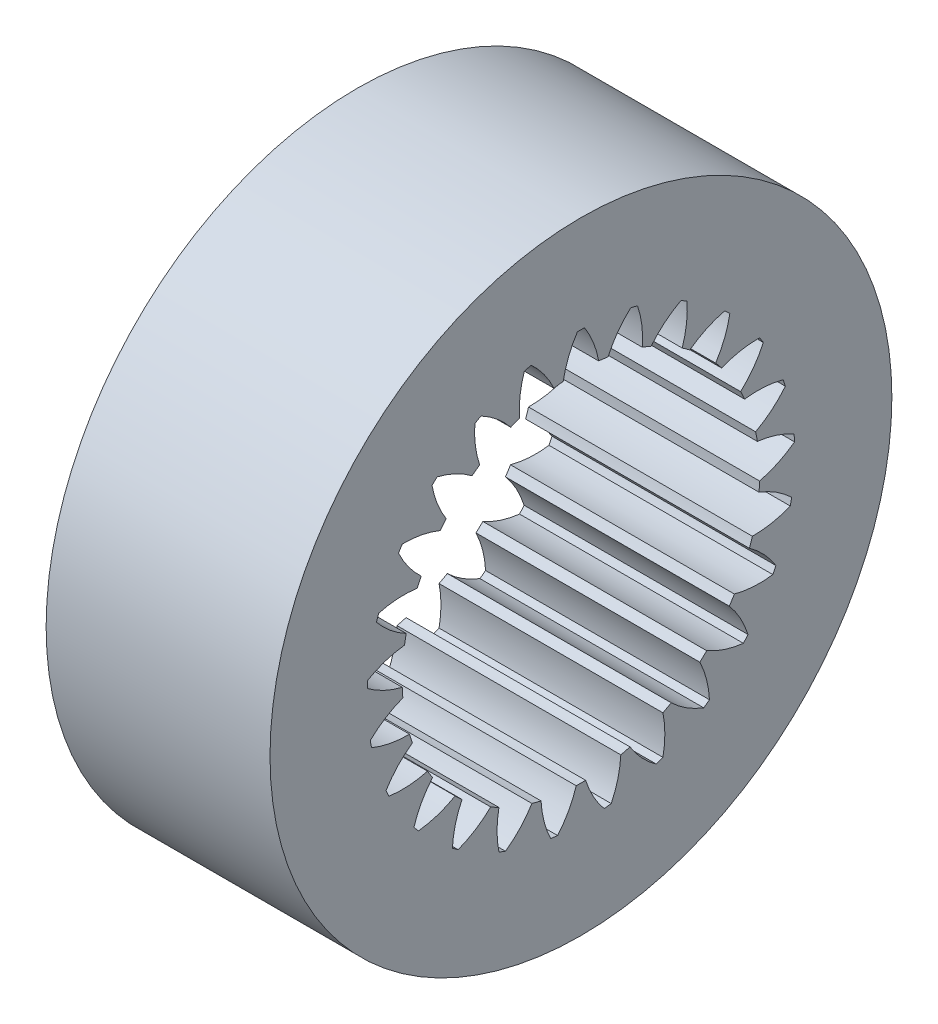
from build123d import *

# Parameters (mm, degrees)
SKETCH1_R           = 5
BOSS_EXTRUDE1_DEPTH = 3.6


with BuildPart() as part:
    # Sketch1 → Boss-Extrude1 (new body)
    with BuildSketch(Plane(origin=(0.839797347, 0, 0), x_dir=(0, 0, -1), z_dir=(1, 0, 0))):
        with Locations((0.288939632, 1.171096215)):
            Circle(SKETCH1_R)
        with BuildLine():
            ThreePointArc((0.724361258, 4.012932419), (0.881490528, 4.282366003), (1.089004557, 4.515222165))
            ThreePointArc((1.089004557, 4.515222165), (1.144059809, 4.501569415), (1.198882356, 4.487010341))
            ThreePointArc((1.198882356, 4.487010341), (1.268548975, 4.182986285), (1.276441784, 3.871182232))
            ThreePointArc((1.276441784, 3.871182232), (1.347297721, 3.844203612), (1.417417612, 3.815365953))
            ThreePointArc((1.417417612, 3.815365953), (1.636615785, 4.037258326), (1.895519351, 4.211192243))
            ThreePointArc((1.895519351, 4.211192243), (1.94544964, 4.184276734), (1.994929142, 4.156541247))
            ThreePointArc((1.994929142, 4.156541247), (1.986799348, 3.844743283), (1.916901675, 3.540772266))
            ThreePointArc((1.916901675, 3.540772266), (1.978822232, 3.497020074), (2.039567544, 3.451650296))
            ThreePointArc((2.039567544, 3.451650296), (2.307061592, 3.612059143), (2.601086833, 3.716141906))
            ThreePointArc((2.601086833, 3.716141906), (2.642754856, 3.677654841), (2.683782333, 3.638485663))
            ThreePointArc((2.683782333, 3.638485663), (2.59836695, 3.338505203), (2.455070724, 3.061466838))
            ThreePointArc((2.455070724, 3.061466838), (2.504165205, 3.003690186), (2.551719086, 2.944639038))
            ThreePointArc((2.551719086, 2.944639038), (2.850701375, 3.033485281), (3.161373603, 3.061176989))
            ThreePointArc((3.161373603, 3.061176989), (3.192161204, 3.01353665), (3.222158749, 2.965394925))
            ThreePointArc((3.222158749, 2.965394925), (3.064824741, 2.696080845), (2.857133789, 2.463382472))
            ThreePointArc((2.857133789, 2.463382472), (2.890317408, 2.395211678), (2.921691873, 2.326189562))
            ThreePointArc((2.921691873, 2.326189562), (3.233376245, 2.337890665), (3.541174782, 2.287451346))
            ThreePointArc((3.541174782, 2.287451346), (3.559147463, 2.23365115), (3.57623022, 2.179561801))
            ThreePointArc((3.57623022, 2.179561801), (3.356863461, 1.957836094), (3.097827771, 1.784099008))
            ThreePointArc((3.097827771, 1.784099008), (3.113015478, 1.709817495), (3.126239154, 1.635161322))
            ThreePointArc((3.126239154, 1.635161322), (3.431041335, 1.568982063), (3.716626066, 1.443581004))
            ThreePointArc((3.716626066, 1.443581004), (3.720654538, 1.387001417), (3.723749134, 1.330363074))
            ThreePointArc((3.723749134, 1.330363074), (3.456133244, 1.170157583), (3.16202898, 1.066298324))
            ThreePointArc((3.16202898, 1.066298324), (3.158266476, 0.990573472), (3.152508471, 0.914974166))
            ThreePointArc((3.152508471, 0.914974166), (3.431276619, 0.775072829), (3.676703205, 0.582589441))
            ThreePointArc((3.676703205, 0.582589441), (3.666534344, 0.526785565), (3.655446335, 0.471157025))
            ThreePointArc((3.655446335, 0.471157025), (3.356396605, 0.38253805), (3.045703419, 0.355082476))
            ThreePointArc((3.045703419, 0.355082476), (3.023227116, 0.282672356), (2.998849227, 0.210880099))
            ThreePointArc((2.998849227, 0.210880099), (3.234067313, 0.006047202), (3.423914699, -0.241424077))
            ThreePointArc((3.423914699, -0.241424077), (3.400187452, -0.292945879), (3.375613538, -0.34406927))
            ThreePointArc((3.375613538, -0.34406927), (3.063920362, -0.355533474), (2.756160251, -0.304860227))
            ThreePointArc((2.756160251, -0.304860227), (2.716382418, -0.36940582), (2.674916396, -0.432880057))
            ThreePointArc((2.674916396, -0.432880057), (2.851804803, -0.689774112), (2.974144181, -0.97668375))
            ThreePointArc((2.974144181, -0.97668375), (2.938349417, -1.020686174), (2.901833668, -1.064092145))
            ThreePointArc((2.901833668, -1.064092145), (2.597081874, -0.99768124), (2.311592537, -0.872063158))
            ThreePointArc((2.311592537, -0.872063158), (2.257012561, -0.924688589), (2.20106387, -0.975856485))
            ThreePointArc((2.20106387, -0.975856485), (2.308508049, -1.268670099), (2.355652385, -1.57699051))
            ThreePointArc((2.355652385, -1.57699051), (2.310039222, -1.61070872), (2.263876056, -1.643669916))
            ThreePointArc((2.263876056, -1.643669916), (1.985214321, -1.503556742), (1.739934103, -1.310886872))
            ThreePointArc((1.739934103, -1.310886872), (1.673981445, -1.34828549), (1.607065546, -1.383931979))
            ThreePointArc((1.607065546, -1.383931979), (1.638314384, -1.694266596), (1.607301426, -2.004624873))
            ThreePointArc((1.607301426, -2.004624873), (1.554735906, -2.025940232), (1.501825925, -2.046385578))
            ThreePointArc((1.501825925, -2.046385578), (1.26676359, -1.841373962), (1.077104349, -1.593758461))
            ThreePointArc((1.077104349, -1.593758461), (1.003923057, -1.613580373), (0.930244524, -1.631465655))
            ThreePointArc((0.930244524, -1.631465655), (0.883334541, -1.939821809), (0.776112947, -2.232717001))
            ThreePointArc((0.776112947, -2.232717001), (0.719897956, -2.240290185), (0.663565687, -2.246935026))
            ThreePointArc((0.663565687, -2.246935026), (0.486872584, -1.989906601), (0.364751308, -1.702904061))
            ThreePointArc((0.364751308, -1.702904061), (0.288939632, -1.703903785), (0.213127956, -1.702904061))
            ThreePointArc((0.213127956, -1.702904061), (0.09100668, -1.989906601), (-0.085686424, -2.246935026))
            ThreePointArc((-0.085686424, -2.246935026), (-0.142018692, -2.240290185), (-0.198233683, -2.232717001))
            ThreePointArc((-0.198233683, -2.232717001), (-0.305455277, -1.939821809), (-0.35236526, -1.631465655))
            ThreePointArc((-0.35236526, -1.631465655), (-0.426043794, -1.613580373), (-0.499225085, -1.593758461))
            ThreePointArc((-0.499225085, -1.593758461), (-0.688884326, -1.841373962), (-0.923946661, -2.046385578))
            ThreePointArc((-0.923946661, -2.046385578), (-0.976856643, -2.025940232), (-1.029422162, -2.004624873))
            ThreePointArc((-1.029422162, -2.004624873), (-1.060435121, -1.694266596), (-1.029186283, -1.383931979))
            ThreePointArc((-1.029186283, -1.383931979), (-1.096102181, -1.34828549), (-1.162054839, -1.310886872))
            ThreePointArc((-1.162054839, -1.310886872), (-1.407335057, -1.503556742), (-1.685996792, -1.643669916))
            ThreePointArc((-1.685996792, -1.643669916), (-1.732159958, -1.61070872), (-1.777773121, -1.57699051))
            ThreePointArc((-1.777773121, -1.57699051), (-1.730628785, -1.268670099), (-1.623184606, -0.975856485))
            ThreePointArc((-1.623184606, -0.975856485), (-1.679133298, -0.924688589), (-1.733713273, -0.872063158))
            ThreePointArc((-1.733713273, -0.872063158), (-2.01920261, -0.99768124), (-2.323954404, -1.064092145))
            ThreePointArc((-2.323954404, -1.064092145), (-2.360470153, -1.020686174), (-2.396264917, -0.97668375))
            ThreePointArc((-2.396264917, -0.97668375), (-2.273925539, -0.689774112), (-2.097037132, -0.432880057))
            ThreePointArc((-2.097037132, -0.432880057), (-2.138503154, -0.36940582), (-2.178280987, -0.304860227))
            ThreePointArc((-2.178280987, -0.304860227), (-2.486041098, -0.355533474), (-2.797734274, -0.34406927))
            ThreePointArc((-2.797734274, -0.34406927), (-2.822308188, -0.292945879), (-2.846035436, -0.241424077))
            ThreePointArc((-2.846035436, -0.241424077), (-2.656188049, 0.006047202), (-2.420969963, 0.210880099))
            ThreePointArc((-2.420969963, 0.210880099), (-2.445347852, 0.282672356), (-2.467824155, 0.355082476))
            ThreePointArc((-2.467824155, 0.355082476), (-2.778517341, 0.38253805), (-3.077567071, 0.471157025))
            ThreePointArc((-3.077567071, 0.471157025), (-3.08865508, 0.526785565), (-3.098823941, 0.582589441))
            ThreePointArc((-3.098823941, 0.582589441), (-2.853397355, 0.775072829), (-2.574629207, 0.914974166))
            ThreePointArc((-2.574629207, 0.914974166), (-2.580387212, 0.990573472), (-2.584149716, 1.066298324))
            ThreePointArc((-2.584149716, 1.066298324), (-2.878253981, 1.170157583), (-3.14586987, 1.330363074))
            ThreePointArc((-3.14586987, 1.330363074), (-3.142775274, 1.387001417), (-3.138746802, 1.443581004))
            ThreePointArc((-3.138746802, 1.443581004), (-2.853162071, 1.568982063), (-2.54835989, 1.635161322))
            ThreePointArc((-2.54835989, 1.635161322), (-2.535136214, 1.709817495), (-2.519948507, 1.784099008))
            ThreePointArc((-2.519948507, 1.784099008), (-2.778984197, 1.957836094), (-2.998350957, 2.179561801))
            ThreePointArc((-2.998350957, 2.179561801), (-2.981268199, 2.23365115), (-2.963295518, 2.287451346))
            ThreePointArc((-2.963295518, 2.287451346), (-2.655496982, 2.337890665), (-2.343812609, 2.326189562))
            ThreePointArc((-2.343812609, 2.326189562), (-2.312438144, 2.395211678), (-2.279254525, 2.463382472))
            ThreePointArc((-2.279254525, 2.463382472), (-2.486945477, 2.696080845), (-2.644279485, 2.965394925))
            ThreePointArc((-2.644279485, 2.965394925), (-2.61428194, 3.01353665), (-2.583494339, 3.061176989))
            ThreePointArc((-2.583494339, 3.061176989), (-2.272822111, 3.033485281), (-1.973839822, 2.944639038))
            ThreePointArc((-1.973839822, 2.944639038), (-1.926285941, 3.003690186), (-1.87719146, 3.061466838))
            ThreePointArc((-1.87719146, 3.061466838), (-2.020487687, 3.338505203), (-2.105903069, 3.638485663))
            ThreePointArc((-2.105903069, 3.638485663), (-2.064875592, 3.677654841), (-2.023207569, 3.716141906))
            ThreePointArc((-2.023207569, 3.716141906), (-1.729182328, 3.612059143), (-1.46168828, 3.451650296))
            ThreePointArc((-1.46168828, 3.451650296), (-1.400942968, 3.497020074), (-1.339022412, 3.540772266))
            ThreePointArc((-1.339022412, 3.540772266), (-1.408920084, 3.844743283), (-1.417049878, 4.156541247))
            ThreePointArc((-1.417049878, 4.156541247), (-1.367570376, 4.184276734), (-1.317640087, 4.211192243))
            ThreePointArc((-1.317640087, 4.211192243), (-1.058736521, 4.037258326), (-0.839538348, 3.815365953))
            ThreePointArc((-0.839538348, 3.815365953), (-0.769418457, 3.844203612), (-0.698562521, 3.871182232))
            ThreePointArc((-0.698562521, 3.871182232), (-0.690669711, 4.182986285), (-0.621003093, 4.487010341))
            ThreePointArc((-0.621003093, 4.487010341), (-0.566180545, 4.501569415), (-0.511125293, 4.515222165))
            ThreePointArc((-0.511125293, 4.515222165), (-0.303611264, 4.282366003), (-0.146481994, 4.012932419))
            ThreePointArc((-0.146481994, 4.012932419), (-0.071393415, 4.023425981), (0.003945762, 4.031935864))
            ThreePointArc((0.003945762, 4.031935864), (0.089133119, 4.331981157), (0.232218741, 4.609128354))
            ThreePointArc((0.232218741, 4.609128354), (0.288939632, 4.609596215), (0.345660523, 4.609128354))
            ThreePointArc((0.345660523, 4.609128354), (0.488746144, 4.331981157), (0.573933502, 4.031935864))
            ThreePointArc((0.573933502, 4.031935864), (0.649272678, 4.023425981), (0.724361258, 4.012932419))
        make_face(mode=Mode.SUBTRACT)
    extrude(amount=-BOSS_EXTRUDE1_DEPTH)


solid = part.part
